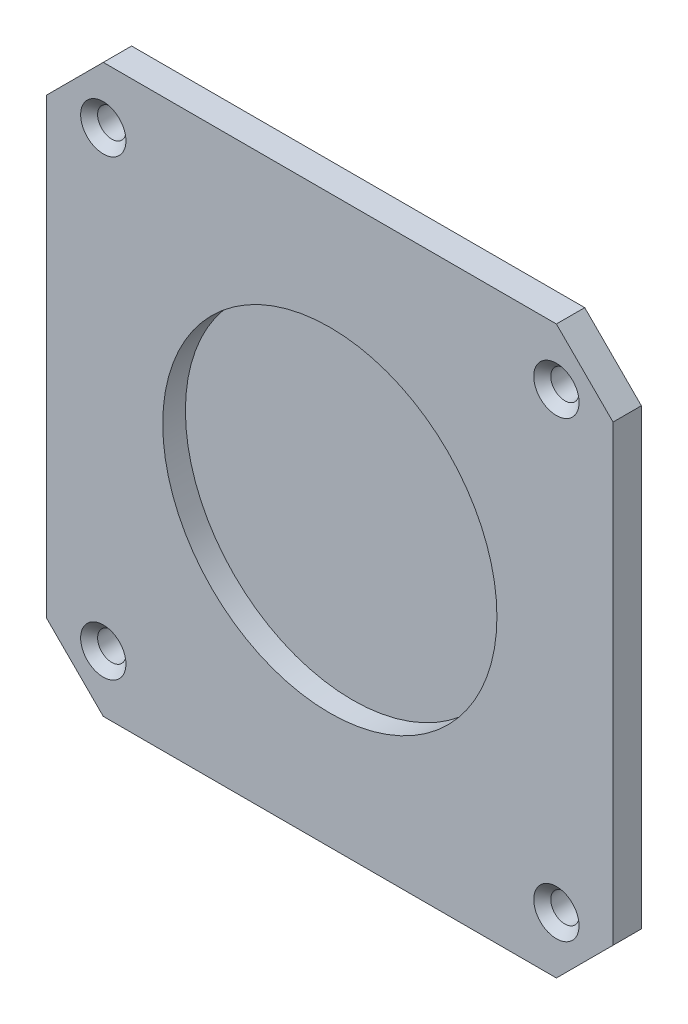
from build123d import *

# Parameters (mm, degrees)
EXTRUDE_1_DEPTH              = 5
SKETCH_2_R                   = 29.5
CUT_EXTRUDE_1_DEPTH          = 4
HOLE_WIZARD_M4_1_D           = 5
HOLE_WIZARD_M4_1_DEPTH       = 5
HOLE_WIZARD_M4_1_CSINK_D     = 8
HOLE_WIZARD_M4_1_CSINK_ANGLE = 90


with BuildPart() as part:
    # 스케치1 → 보스-돌출1 (new body)
    with BuildSketch(Plane.XY):
        Polygon((-50, 40), (-40, 50), (40, 50), (50, 40), (50, -40), (40, -50), (-40, -50), (-50, -40), align=None)
    extrude(amount=EXTRUDE_1_DEPTH)

    # 스케치2 → 컷-돌출1 (cut)
    with BuildSketch(Plane.XY.offset(5)):
        Circle(SKETCH_2_R)
    extrude(amount=-CUT_EXTRUDE_1_DEPTH, mode=Mode.SUBTRACT)

    # M4 납작 십자머리 나사용 카운터싱크1
    with Locations(Plane(origin=(-40, 40, 5), x_dir=(1, 0, 0), z_dir=(0, 0, 1))):
        with Locations((0, 0), (80, 0), (80, -80), (0, -80)):
            CounterSinkHole(HOLE_WIZARD_M4_1_D / 2, HOLE_WIZARD_M4_1_CSINK_D / 2, depth=HOLE_WIZARD_M4_1_DEPTH, counter_sink_angle=HOLE_WIZARD_M4_1_CSINK_ANGLE)


solid = part.part
